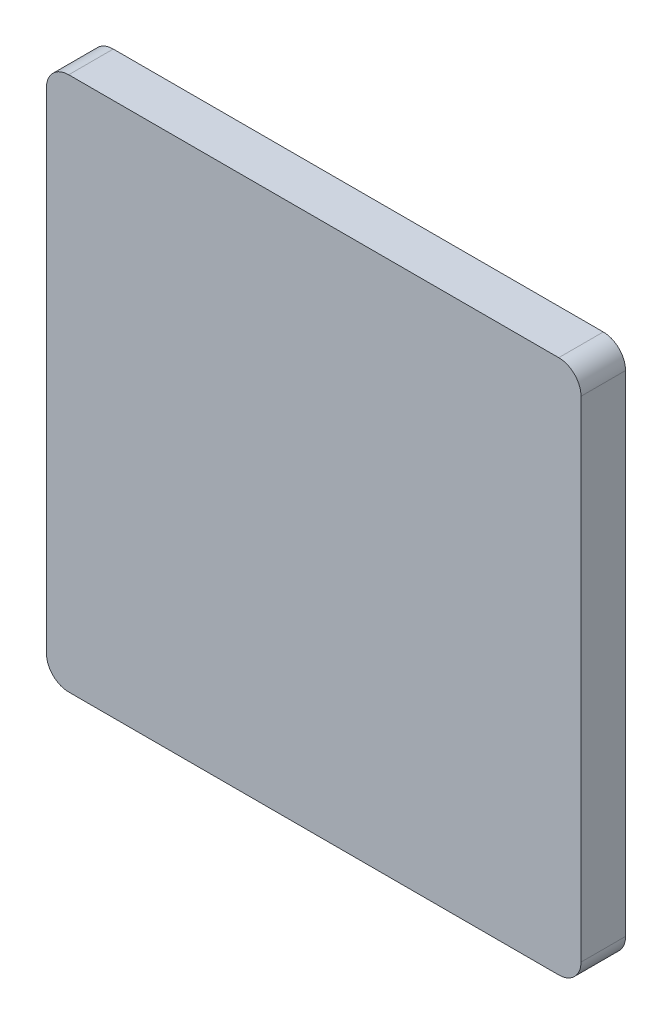
from build123d import *

# Parameters (mm, degrees)
SKETCH1_W           = 76.2
SKETCH1_H           = 76.2
BOSS_EXTRUDE1_DEPTH = 3.175
FILLET1_R           = 3.175


with BuildPart() as part:
    # Sketch1 → Boss-Extrude1 (new body, symmetric)
    with BuildSketch(Plane.XY):
        Rectangle(SKETCH1_W, SKETCH1_H)
    extrude(amount=BOSS_EXTRUDE1_DEPTH, both=True)

    # Fillet1
    fillet1_edges = [part.edges().sort_by_distance(p)[0] for p in [
        (38.1, -38.1, 0),
        (-38.1, -38.1, 0),
        (-38.1, 38.1, 0),
        (38.1, 38.1, 0),
    ]]
    fillet(fillet1_edges, radius=FILLET1_R)


solid = part.part
